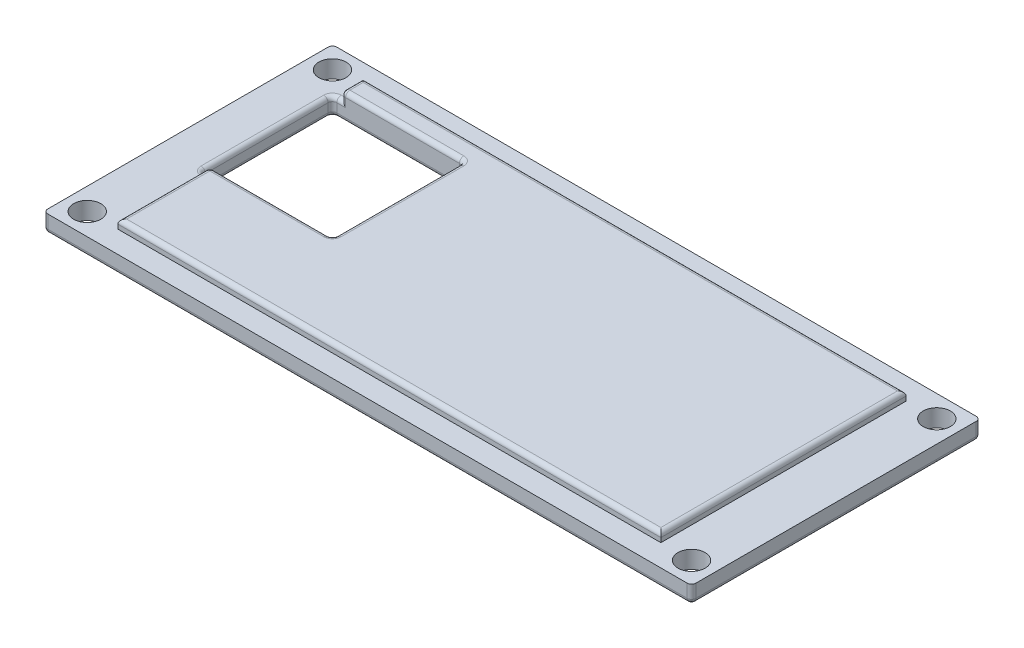
from build123d import *

# Parameters (mm, degrees)
SKETCH1_W           = 74
SKETCH1_H           = 33
BOSS_EXTRUDE1_DEPTH = 2
SKETCH2_W           = 62
SKETCH2_H           = 28
BOSS_EXTRUDE2_DEPTH = 1
SKETCH3_R           = 1.55
CUT_EXTRUDE2_DEPTH  = 5
FILLET1_R           = 0.5
FILLET2_R           = 0.5
SKETCH4_W           = 15
SKETCH4_H           = 15
CUT_EXTRUDE3_DEPTH  = 10
FILLET3_R           = 0.5


with BuildPart() as part:
    # Sketch1 → Boss-Extrude1 (new body)
    with BuildSketch(Plane(origin=(0, 0, 0), x_dir=(1, 0, 0), z_dir=(0, 1, 0))):
        with Locations((37, 16.5)):
            Rectangle(SKETCH1_W, SKETCH1_H)
    extrude(amount=BOSS_EXTRUDE1_DEPTH)

    # Sketch2 → Boss-Extrude2 (add)
    with BuildSketch(Plane(origin=(0, 2, 0), x_dir=(1, 0, 0), z_dir=(0, 1, 0))):
        with Locations((37, 16.5)):
            Rectangle(SKETCH2_W, SKETCH2_H)
    extrude(amount=BOSS_EXTRUDE2_DEPTH)

    # Sketch3 → Cut-Extrude2 (cut)
    with BuildSketch(Plane(origin=(0, 2, 0), x_dir=(1, 0, 0), z_dir=(0, 1, 0))):
        with Locations((2.5, 30.5)):
            Circle(SKETCH3_R)
        with Locations((71.5, 2.5)):
            Circle(SKETCH3_R)
        with Locations((2.5, 2.5)):
            Circle(SKETCH3_R)
        with Locations((71.5, 30.5)):
            Circle(SKETCH3_R)
    extrude(amount=-CUT_EXTRUDE2_DEPTH, mode=Mode.SUBTRACT)

    # Fillet1
    fillet1_edges = [part.edges().sort_by_distance(p)[0] for p in [
        (6, 3, -16.5),
        (37, 3, -2.5),
        (68, 3, -16.5),
        (37, 3, -30.5),
    ]]
    fillet(fillet1_edges, radius=FILLET1_R)

    # Fillet2
    fillet2_edges = [part.edges().sort_by_distance(p)[0] for p in [
        (37, 0, -33),
        (74, 0, -16.5),
        (37, 0, 0),
        (0, 0, -16.5),
        (0, 1, -33),
        (74, 1, -33),
        (74, 1, 0),
        (0, 1, 0),
    ]]
    fillet(fillet2_edges, radius=FILLET2_R)

    # Sketch4 → Cut-Extrude3 (cut)
    with BuildSketch(Plane.XZ):
        with Locations((12.5, -20.5)):
            Rectangle(SKETCH4_W, SKETCH4_H)
    extrude(amount=-CUT_EXTRUDE3_DEPTH, mode=Mode.SUBTRACT)

    # Fillet3
    fillet3_edges = [part.edges().sort_by_distance(p)[0] for p in [
        (13.25, 3, -13),
        (20, 1.5, -13),
        (13.25, 3, -28),
        (5, 0, -20.5),
        (12.5, 0, -28),
        (20, 0, -20.5),
        (12.5, 0, -13),
        (6.146446609, 2.853553391, -28),
        (6.146446609, 2.853553391, -13),
        (20, 3, -20.5),
        (5, 2, -20.5),
        (5, 1, -28),
        (6, 2.25, -13),
        (5.5, 2, -13),
        (5, 1, -13),
        (5.5, 2, -28),
        (6, 2.25, -28),
        (20, 1.5, -28),
    ]]
    fillet(fillet3_edges, radius=FILLET3_R)


solid = part.part
